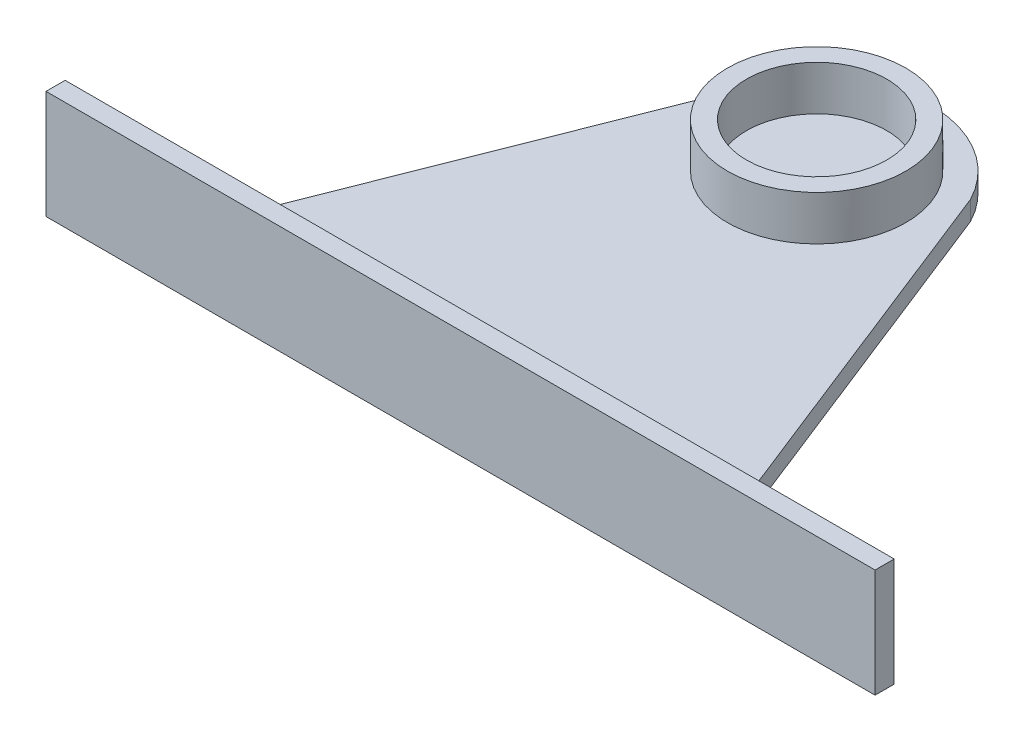
from build123d import *

# Parameters (mm, degrees)
BOSS_EXTRUDE1_DEPTH = 3
SKETCH2_R           = 14
SKETCH2_R_2         = 11
BOSS_EXTRUDE2_DEPTH = 7
SKETCH3_W           = 130
SKETCH3_H           = 17
BOSS_EXTRUDE3_DEPTH = 3


with BuildPart() as part:
    # Sketch1 → Boss-Extrude1 (new body)
    with BuildSketch(Plane(origin=(0, 0, 0), x_dir=(1, 0, 0), z_dir=(0, 1, 0))):
        with BuildLine():
            Line((-48.929144451, -17.835062273), (31.070855549, -17.835062273))
            Line((31.070855549, -17.835062273), (6.985518971, 43.196988966))
            ThreePointArc((6.985518971, 43.196988966), (-8.929144451, 52.904273338), (-24.843807874, 43.196988966))
            Line((-24.843807874, 43.196988966), (-48.929144451, -17.835062273))
        make_face()
    extrude(amount=BOSS_EXTRUDE1_DEPTH)

    # Sketch2 → Boss-Extrude2 (add)
    with BuildSketch(Plane(origin=(0, 3, 0), x_dir=(1, 0, 0), z_dir=(0, 1, 0))):
        with Locations((-8.929144451, 35.004937727)):
            Circle(SKETCH2_R)
        with Locations((-8.929144451, 35.004937727)):
            Circle(SKETCH2_R_2, mode=Mode.SUBTRACT)
    extrude(amount=BOSS_EXTRUDE2_DEPTH)

    # Sketch3 → Boss-Extrude3 (add)
    with BuildSketch(Plane.XY.offset(17.835062273)):
        with Locations((-8.929144451, 0.75050315)):
            Rectangle(SKETCH3_W, SKETCH3_H)
    extrude(amount=BOSS_EXTRUDE3_DEPTH)


solid = part.part
